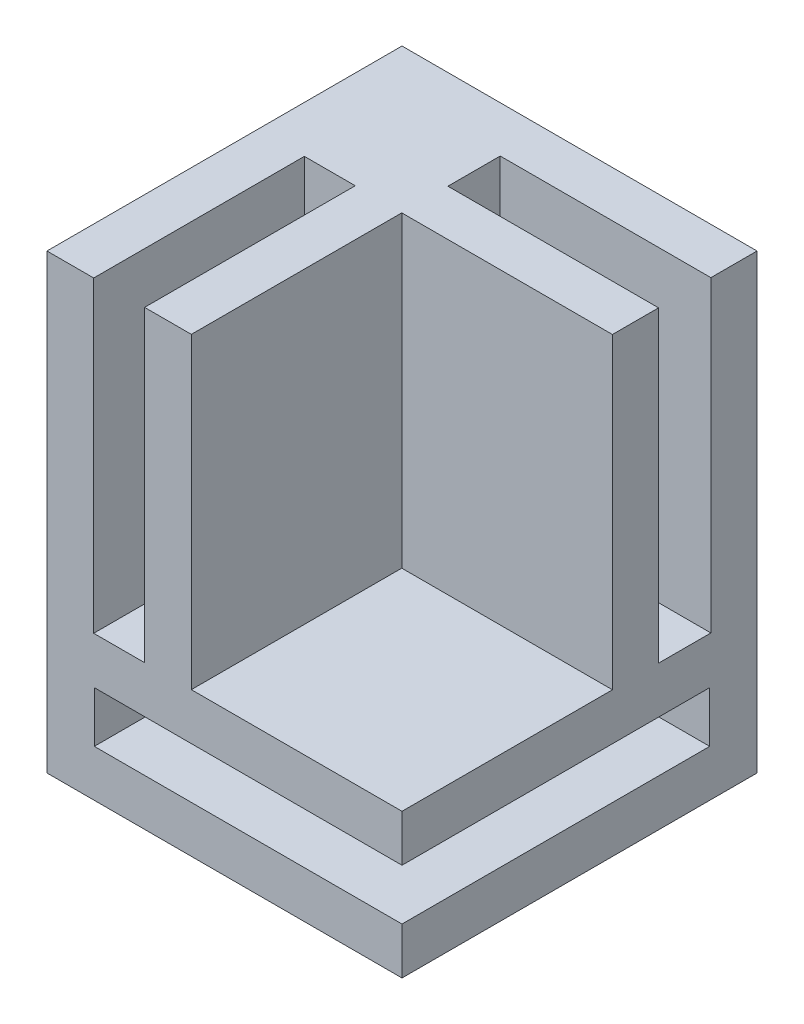
from build123d import *

# Parameters (mm, degrees)
SKETCH1_W           = 30
SKETCH1_H           = 12.2
BOSS_EXTRUDE1_DEPTH = 30
SKETCH2_W           = 26
SKETCH2_H           = 4.3
CUT_EXTRUDE1_DEPTH  = 26
SKETCH3_W           = 30
SKETCH3_H           = 30
BOSS_EXTRUDE2_DEPTH = 26
SKETCH4_W           = 17.8
SKETCH4_H           = 17.78
CUT_EXTRUDE2_DEPTH  = 26
SKETCH6_W           = 4.42
SKETCH6_H           = 26
CUT_EXTRUDE3_DEPTH  = 17.8
SKETCH9_W           = 4.3
SKETCH9_H           = 26
CUT_EXTRUDE4_DEPTH  = 17.8


with BuildPart() as part:
    # Sketch1 → Boss-Extrude1 (new body)
    with BuildSketch(Plane.XY):
        with Locations((-26.249929658, 18.197752809)):
            Rectangle(SKETCH1_W, SKETCH1_H)
    extrude(amount=BOSS_EXTRUDE1_DEPTH)

    # Sketch2 → Cut-Extrude1 (cut)
    with BuildSketch(Plane(origin=(-11.249929658, 0, 0), x_dir=(0, 0, -1), z_dir=(1, 0, 0))):
        with Locations((-17, 18.197752809)):
            Rectangle(SKETCH2_W, SKETCH2_H)
    extrude(amount=-CUT_EXTRUDE1_DEPTH, mode=Mode.SUBTRACT)

    # Sketch3 → Boss-Extrude2 (add)
    with BuildSketch(Plane(origin=(0, 24.297752809, 0), x_dir=(1, 0, 0), z_dir=(0, 1, 0))):
        with Locations((-26.249929658, -15)):
            Rectangle(SKETCH3_W, SKETCH3_H)
    extrude(amount=BOSS_EXTRUDE2_DEPTH)

    # Sketch4 → Cut-Extrude2 (cut)
    with BuildSketch(Plane(origin=(0, 50.297752809, 0), x_dir=(1, 0, 0), z_dir=(0, 1, 0))):
        with Locations((-20.149929658, -21.11)):
            Rectangle(SKETCH4_W, SKETCH4_H)
    extrude(amount=-CUT_EXTRUDE2_DEPTH, mode=Mode.SUBTRACT)

    # Sketch6 → Cut-Extrude3 (cut)
    with BuildSketch(Plane(origin=(-11.249929658, 0, 0), x_dir=(0, 0, -1), z_dir=(1, 0, 0))):
        with Locations((-6.11, 37.297752809)):
            Rectangle(SKETCH6_W, SKETCH6_H)
    extrude(amount=-CUT_EXTRUDE3_DEPTH, mode=Mode.SUBTRACT)

    # Sketch9 → Cut-Extrude4 (cut)
    with BuildSketch(Plane.XY.offset(30)):
        with Locations((-35.149929658, 37.297752809)):
            Rectangle(SKETCH9_W, SKETCH9_H)
    extrude(amount=-CUT_EXTRUDE4_DEPTH, mode=Mode.SUBTRACT)


solid = part.part
